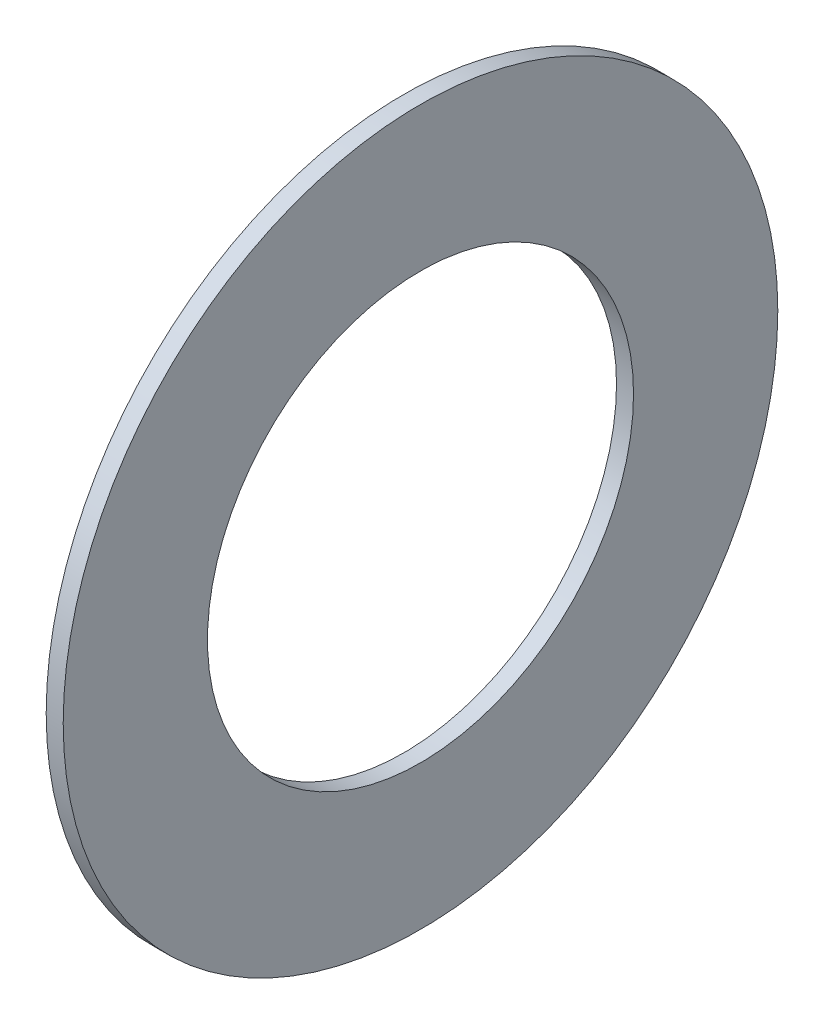
from build123d import *

# Parameters (mm, degrees)
SKETCH3_R                = 21
SKETCH3_R_2              = 12.52
BOSS_EXTRUDE1_DEPTH      = 0.5
BOSS_EXTRUDE1_DEPTH_BACK = 0.5


with BuildPart() as part:
    # Sketch3 → Boss-Extrude1 (new body, two sides)
    with BuildSketch(Plane(origin=(0, 0, 0), x_dir=(0, 0, -1), z_dir=(1, 0, 0))) as boss_extrude1_sk:
        Circle(SKETCH3_R)
        Circle(SKETCH3_R_2, mode=Mode.SUBTRACT)
    extrude(amount=BOSS_EXTRUDE1_DEPTH)
    extrude(boss_extrude1_sk.sketch, amount=-BOSS_EXTRUDE1_DEPTH_BACK)


solid = part.part
